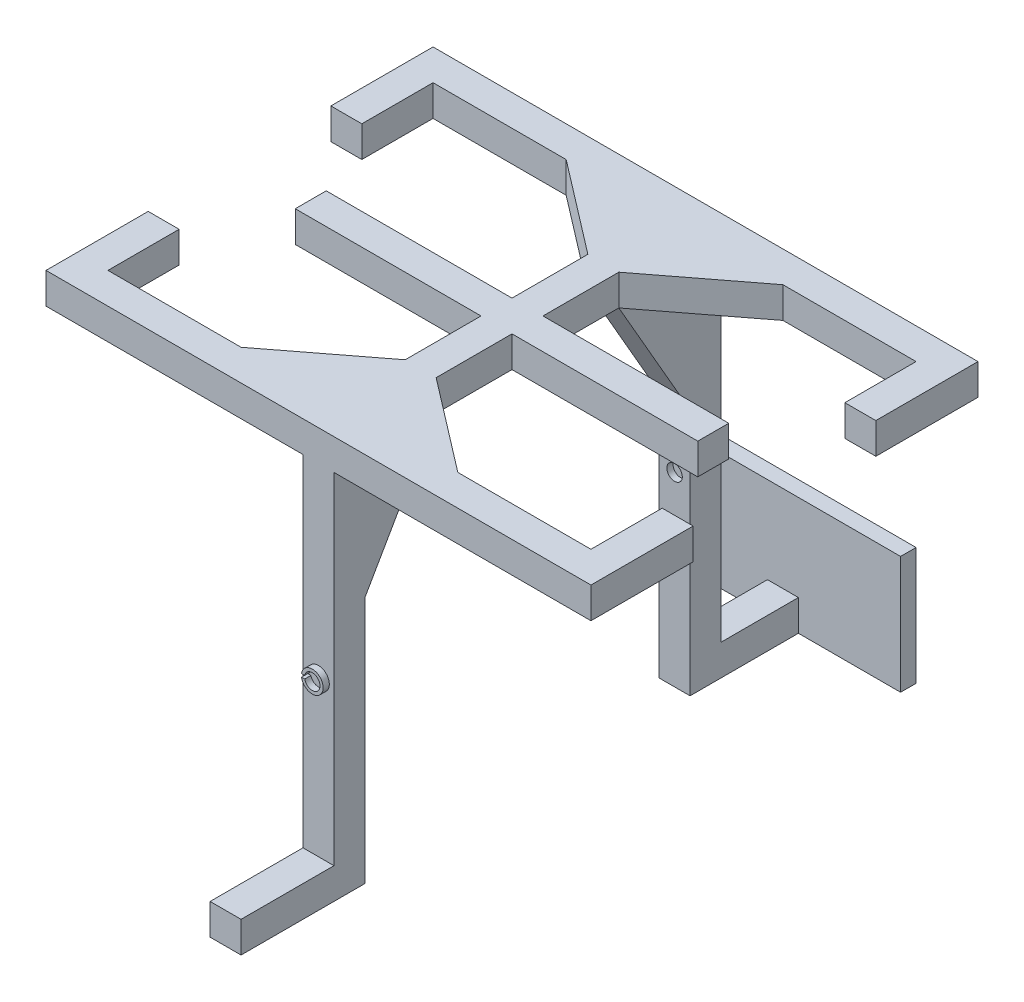
from build123d import *

# Parameters (mm, degrees)
SKETCH1_W            = 176
SKETCH1_H            = 10
BOSS_EXTRUDE1_DEPTH  = 10
SKETCH2_W            = 10
SKETCH2_H            = 10
BOSS_EXTRUDE2_DEPTH  = 52.5
SKETCH3_W            = 10
SKETCH3_H            = 10
BOSS_EXTRUDE3_DEPTH  = 23
SKETCH4_W            = 10
SKETCH4_H            = 10
BOSS_EXTRUDE4_DEPTH  = 120
BOSS_EXTRUDE5_DEPTH  = 10
SKETCH17_W           = 10
SKETCH17_H           = 10
BOSS_EXTRUDE6_DEPTH  = 20
CUT_REVOLVE2_ANGLE   = 180
LPATTERN1_COUNT      = 3
LPATTERN1_PITCH      = 20
SKETCH23_W           = 10
SKETCH23_H           = 10
BOSS_EXTRUDE7_DEPTH  = 20
CUT_REVOLVE3_ANGLE   = 180
LPATTERN2_COUNT      = 3
LPATTERN2_PITCH      = 20
SKETCH25_W           = 10
SKETCH25_H           = 10
BOSS_EXTRUDE8_DEPTH  = 30
SKETCH27_W           = 10
SKETCH27_H           = 10
BOSS_EXTRUDE10_DEPTH = 30
SKETCH28_W           = 76
SKETCH28_H           = 38
BOSS_EXTRUDE11_DEPTH = 5
BOSS_EXTRUDE12_DEPTH = 10
CIRPATTERN2_COUNT    = 2
SKETCH31_R           = 3.5
SKETCH31_R_2         = 2.5
BOSS_EXTRUDE13_DEPTH = 2
SKETCH32_R           = 3.5
SKETCH32_R_2         = 2.5
BOSS_EXTRUDE14_DEPTH = 2
SKETCH33_R           = 2.5
CUT_EXTRUDE1_DEPTH   = 2
SKETCH34_R           = 2.5
CUT_EXTRUDE2_DEPTH   = 2
SKETCH35_W           = 2.388589586
SKETCH35_H           = 1
CUT_EXTRUDE3_DEPTH   = 2
SKETCH37_W           = 2.280099824
SKETCH37_H           = 1
CUT_EXTRUDE4_DEPTH   = 2
CUT_REVOLVE4_ANGLE   = 180
CUT_REVOLVE5_ANGLE   = 180
CUT_REVOLVE8_ANGLE   = 180
CUT_REVOLVE9_ANGLE   = 180


with BuildPart() as part:
    # Sketch1 → Boss-Extrude1 (new body)
    with BuildSketch(Plane.XY):
        with Locations((88, 5)):
            Rectangle(SKETCH1_W, SKETCH1_H)
    extrude(amount=BOSS_EXTRUDE1_DEPTH)

    # Sketch2 → Boss-Extrude2 (add)
    with BuildSketch(Plane(origin=(0, 0, 0), x_dir=(-1, 0, 0), z_dir=(0, 0, -1))):
        with Locations((-88, 5)):
            Rectangle(SKETCH2_W, SKETCH2_H)
    extrude(amount=BOSS_EXTRUDE2_DEPTH)

    # Sketch3 → Boss-Extrude3 (add)
    with BuildSketch(Plane(origin=(0, 0, 0), x_dir=(-1, 0, 0), z_dir=(0, 0, -1))):
        with Locations((-5, 5)):
            Rectangle(SKETCH3_W, SKETCH3_H)
        with Locations((-171, 5)):
            Rectangle(SKETCH3_W, SKETCH3_H)
    extrude(amount=BOSS_EXTRUDE3_DEPTH)

    # Mirror6: part across plane


with BuildPart() as part_1:
    add(part.part)
    add(part.part.mirror(Plane.XY.offset(-52.5)))

    # Sketch4 → Boss-Extrude4 (add)
    with BuildSketch(Plane.XZ):
        with Locations((88, 5)):
            Rectangle(SKETCH4_W, SKETCH4_H)
        with Locations((88, -110)):
            Rectangle(SKETCH4_W, SKETCH4_H)
    extrude(amount=BOSS_EXTRUDE4_DEPTH)

    # Sketch13 → Boss-Extrude5 (add)
    with BuildSketch(Plane.ZY.offset(-83)):
        Polygon((-105, 0), (-82, 0), (-105, -40), align=None)
        Polygon((0, -40), (0, 0), (-23, 0), align=None)
    extrude(amount=-BOSS_EXTRUDE5_DEPTH)

    # Sketch17 → Boss-Extrude6 (add)
    with BuildSketch(Plane.ZY.offset(-83)):
        with Locations((-52.5, 5)):
            Rectangle(SKETCH17_W, SKETCH17_H)
    boss_extrude6 = extrude(amount=BOSS_EXTRUDE6_DEPTH)

    # Sketch18 → Cut-Revolve2 (revolve, cut)
    with BuildSketch(Plane.XZ):
        with BuildLine():
            Line((71, -52.5), (65, -52.5))
            ThreePointArc((65, -52.5), (68, -55.5), (71, -52.5))
        make_face()
    cut_revolve2 = revolve(axis=Axis((71, 0, -52.5), (1, 0, 0)), revolution_arc=CUT_REVOLVE2_ANGLE, mode=Mode.SUBTRACT)

    # LPattern1: Boss-Extrude6, Cut-Revolve2 ×3
    with Locations(*[(-i * LPATTERN1_PITCH, 0, 0) for i in range(1, LPATTERN1_COUNT)]):
        add(boss_extrude6)
        add(cut_revolve2, mode=Mode.SUBTRACT)

    # Sketch23 → Boss-Extrude7 (add)
    with BuildSketch(Plane(origin=(93, 0, 0), x_dir=(0, 0, -1), z_dir=(1, 0, 0))):
        with Locations((52.5, 5)):
            Rectangle(SKETCH23_W, SKETCH23_H)
    boss_extrude7 = extrude(amount=BOSS_EXTRUDE7_DEPTH)

    # Sketch24 → Cut-Revolve3 (revolve, cut)
    with BuildSketch(Plane.XZ):
        with BuildLine():
            ThreePointArc((105, -52.5), (108, -49.5), (111, -52.5))
            Line((111, -52.5), (105, -52.5))
        make_face()
    cut_revolve3 = revolve(axis=Axis((111, 0, -52.5), (-1, 0, 0)), revolution_arc=CUT_REVOLVE3_ANGLE, mode=Mode.SUBTRACT)

    # LPattern2: Boss-Extrude7, Cut-Revolve3 ×3
    with Locations(*[(i * LPATTERN2_PITCH, 0, 0) for i in range(1, LPATTERN2_COUNT)]):
        add(boss_extrude7)
        add(cut_revolve3, mode=Mode.SUBTRACT)

    # Sketch25 → Boss-Extrude8 (add)
    with BuildSketch(Plane(origin=(0, 0, -115), x_dir=(-1, 0, 0), z_dir=(0, 0, -1))):
        with Locations((-88, -115)):
            Rectangle(SKETCH25_W, SKETCH25_H)
    extrude(amount=BOSS_EXTRUDE8_DEPTH)

    # Sketch27 → Boss-Extrude10 (add)
    with BuildSketch(Plane.XY.offset(10)):
        with Locations((88, -115)):
            Rectangle(SKETCH27_W, SKETCH27_H)
    extrude(amount=BOSS_EXTRUDE10_DEPTH)

    # Sketch28 → Boss-Extrude11 (add)
    with BuildSketch(Plane(origin=(0, 0, -145), x_dir=(-1, 0, 0), z_dir=(0, 0, -1))):
        with Locations((-88, -101)):
            Rectangle(SKETCH28_W, SKETCH28_H)
    extrude(amount=-BOSS_EXTRUDE11_DEPTH)

    # Sketch30 → Boss-Extrude12 (add)
    with BuildSketch(Plane.XZ):
        Polygon((93, -105), (123, -105), (93, -82), align=None)
        Polygon((93, 0), (93, -23), (123, 0), align=None)
    boss_extrude12 = extrude(amount=-BOSS_EXTRUDE12_DEPTH)

    # CirPattern2: Boss-Extrude12 ×2 about axis
    cirpattern2_axis = Axis((88, 0, -52.5), (0, 1, 0))
    for i in range(1, CIRPATTERN2_COUNT):
        add(boss_extrude12.rotate(cirpattern2_axis, i * 360 / CIRPATTERN2_COUNT))

    # Sketch31 → Boss-Extrude13 (add)
    with BuildSketch(Plane(origin=(0, 0, -115), x_dir=(-1, 0, 0), z_dir=(0, 0, -1))):
        with Locations((-88, -60)):
            Circle(SKETCH31_R)
        with Locations((-88, -60)):
            Circle(SKETCH31_R_2, mode=Mode.SUBTRACT)
    extrude(amount=BOSS_EXTRUDE13_DEPTH)

    # Sketch32 → Boss-Extrude14 (add)
    with BuildSketch(Plane.XY.offset(10)):
        with Locations((88, -60)):
            Circle(SKETCH32_R)
        with Locations((88, -60)):
            Circle(SKETCH32_R_2, mode=Mode.SUBTRACT)
    extrude(amount=BOSS_EXTRUDE14_DEPTH)

    # Sketch33 → Cut-Extrude1 (cut)
    with BuildSketch(Plane.XY.offset(-105)):
        with Locations((88, -60)):
            Circle(SKETCH33_R)
    extrude(amount=-CUT_EXTRUDE1_DEPTH, mode=Mode.SUBTRACT)

    # Sketch34 → Cut-Extrude2 (cut)
    with BuildSketch(Plane(origin=(0, 0, 0), x_dir=(-1, 0, 0), z_dir=(0, 0, -1))):
        with Locations((-88, -60)):
            Circle(SKETCH34_R)
    extrude(amount=-CUT_EXTRUDE2_DEPTH, mode=Mode.SUBTRACT)

    # Sketch35 → Cut-Extrude3 (cut)
    with BuildSketch(Plane.XY.offset(12)):
        with Locations((85.5, -60)):
            Rectangle(SKETCH35_W, SKETCH35_H)
    extrude(amount=-CUT_EXTRUDE3_DEPTH, mode=Mode.SUBTRACT)

    # Sketch37 → Cut-Extrude4 (cut)
    with BuildSketch(Plane(origin=(0, 0, -117), x_dir=(-1, 0, 0), z_dir=(0, 0, -1))):
        with Locations((-91, -60)):
            Rectangle(SKETCH37_W, SKETCH37_H)
    extrude(amount=-CUT_EXTRUDE4_DEPTH, mode=Mode.SUBTRACT)

    # Sketch40 → Cut-Revolve4 (revolve, cut)
    with BuildSketch(Plane.XZ):
        with BuildLine():
            ThreePointArc((100.558437384, -100.017733807), (103.558437384, -97.017733807), (106.558437384, -100.017733807))
            Line((106.558437384, -100.017733807), (103.558437384, -100.017733807))
            Line((103.558437384, -100.017733807), (100.558437384, -100.017733807))
        make_face()
    revolve(axis=Axis((103.558437384, 0, -100.017733807), (-1, 0, 0)), revolution_arc=CUT_REVOLVE4_ANGLE, mode=Mode.SUBTRACT)

    # Sketch20 → Cut-Revolve5 (revolve, cut)
    with BuildSketch(Plane.XZ):
        with BuildLine():
            ThreePointArc((2.994783484, -15.417059662), (5.994783484, -12.417059662), (8.994783484, -15.417059662))
            Line((8.994783484, -15.417059662), (2.994783484, -15.417059662))
        make_face()
    revolve(axis=Axis((2.994783484, 0, -15.417059662), (-1, 0, 0)), revolution_arc=CUT_REVOLVE5_ANGLE, mode=Mode.SUBTRACT)

    # Sketch42 → Cut-Revolve8 (revolve, cut)
    with BuildSketch(Plane.XZ.offset(120)):
        with BuildLine():
            Line((88, 38), (88, 32))
            ThreePointArc((88, 32), (85, 35), (88, 38))
        make_face()
    revolve(axis=Axis((88, -120, 38), (0, 0, -1)), revolution_arc=CUT_REVOLVE8_ANGLE, mode=Mode.SUBTRACT)

    # Sketch44 → Cut-Revolve9 (revolve, cut)
    with BuildSketch(Plane.XZ.offset(120)):
        with BuildLine():
            Line((88, -107), (88, -113))
            ThreePointArc((88, -113), (85, -110), (88, -107))
        make_face()
    revolve(axis=Axis((88, -120, -107), (0, 0, -1)), revolution_arc=CUT_REVOLVE9_ANGLE, mode=Mode.SUBTRACT)


solid = part_1.part
